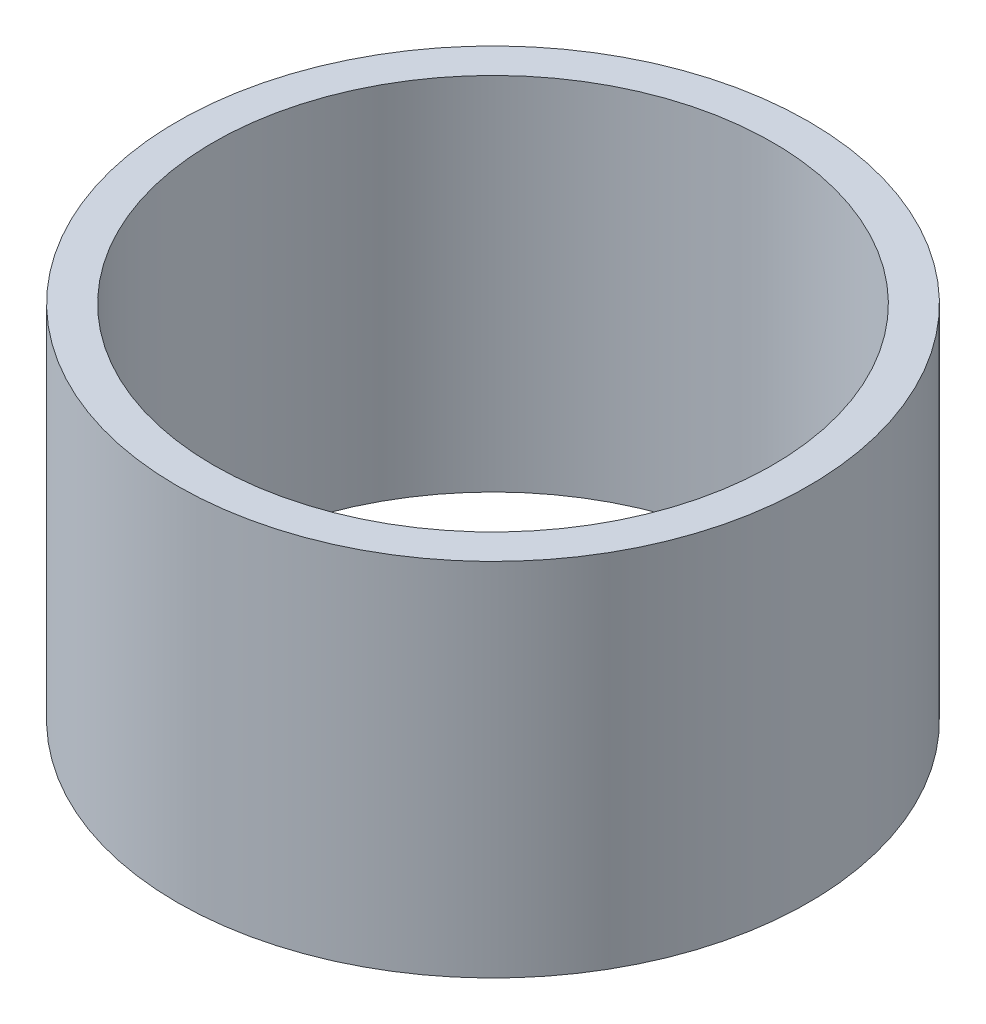
from build123d import *

# Parameters (mm, degrees)
SKETCH1_R           = 55.5625
SKETCH1_R_2         = 49.2125
BOSS_EXTRUDE1_DEPTH = 63.5


with BuildPart() as part:
    # Sketch1 → Boss-Extrude1 (new body)
    with BuildSketch(Plane(origin=(0, 0, 0), x_dir=(1, 0, 0), z_dir=(0, 1, 0))):
        Circle(SKETCH1_R)
        Circle(SKETCH1_R_2, mode=Mode.SUBTRACT)
    extrude(amount=BOSS_EXTRUDE1_DEPTH)


solid = part.part
